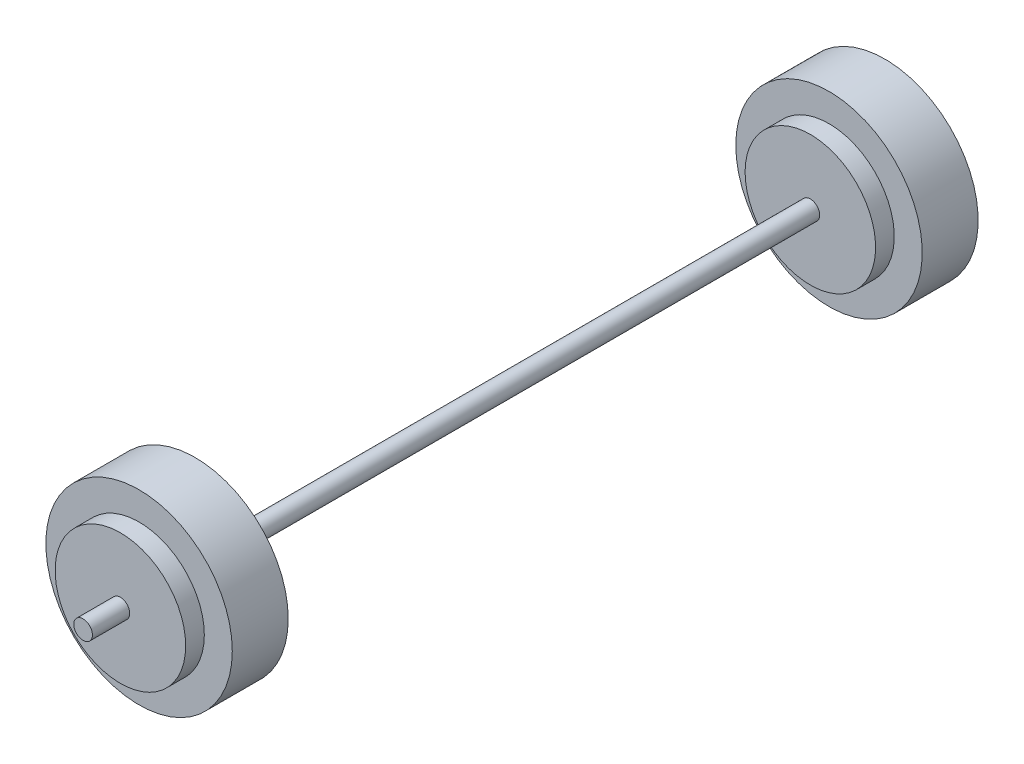
from build123d import *

# Parameters (mm, degrees)
SKETCH1_R           = 127
BOSS_EXTRUDE1_DEPTH = 76.2
SKETCH2_R           = 88.9
BOSS_EXTRUDE2_DEPTH = 25.4
SKETCH3_R           = 12.7
BOSS_EXTRUDE3_DEPTH = 50.8
SKETCH4_R           = 88.9
BOSS_EXTRUDE4_DEPTH = 25.4
SKETCH6_R           = 12.7
BOSS_EXTRUDE5_DEPTH = 812.8
SKETCH7_R           = 88.9
BOSS_EXTRUDE6_DEPTH = 25.4
SKETCH8_R           = 127
BOSS_EXTRUDE7_DEPTH = 76.2
SKETCH9_R           = 88.9
BOSS_EXTRUDE8_DEPTH = 25.4
SKETCH10_R          = 12.7
BOSS_EXTRUDE9_DEPTH = 50.8


with BuildPart() as part:
    # Sketch1 → Boss-Extrude1 (new body)
    with BuildSketch(Plane.XY):
        Circle(SKETCH1_R)
    extrude(amount=-BOSS_EXTRUDE1_DEPTH)

    # Sketch2 → Boss-Extrude2 (add)
    with BuildSketch(Plane.XY):
        Circle(SKETCH2_R)
    extrude(amount=BOSS_EXTRUDE2_DEPTH)

    # Sketch3 → Boss-Extrude3 (add)
    with BuildSketch(Plane.XY.offset(25.4)):
        Circle(SKETCH3_R)
    extrude(amount=BOSS_EXTRUDE3_DEPTH)

    # Sketch4 → Boss-Extrude4 (add)
    with BuildSketch(Plane(origin=(0, 0, -76.2), x_dir=(-1, 0, 0), z_dir=(0, 0, -1))):
        Circle(SKETCH4_R)
    extrude(amount=BOSS_EXTRUDE4_DEPTH)

    # Sketch6 → Boss-Extrude5 (add)
    with BuildSketch(Plane(origin=(0, 0, -101.6), x_dir=(-1, 0, 0), z_dir=(0, 0, -1))):
        Circle(SKETCH6_R)
    extrude(amount=BOSS_EXTRUDE5_DEPTH)

    # Sketch7 → Boss-Extrude6 (add)
    with BuildSketch(Plane(origin=(0, 0, -914.4), x_dir=(-1, 0, 0), z_dir=(0, 0, -1))):
        Circle(SKETCH7_R)
    extrude(amount=BOSS_EXTRUDE6_DEPTH)

    # Sketch8 → Boss-Extrude7 (add)
    with BuildSketch(Plane(origin=(0, 0, -939.8), x_dir=(-1, 0, 0), z_dir=(0, 0, -1))):
        Circle(SKETCH8_R)
    extrude(amount=BOSS_EXTRUDE7_DEPTH)

    # Sketch9 → Boss-Extrude8 (add)
    with BuildSketch(Plane(origin=(0, 0, -1016), x_dir=(-1, 0, 0), z_dir=(0, 0, -1))):
        Circle(SKETCH9_R)
    extrude(amount=BOSS_EXTRUDE8_DEPTH)

    # Sketch10 → Boss-Extrude9 (add)
    with BuildSketch(Plane(origin=(0, 0, -1041.4), x_dir=(-1, 0, 0), z_dir=(0, 0, -1))):
        Circle(SKETCH10_R)
    extrude(amount=BOSS_EXTRUDE9_DEPTH)


solid = part.part
